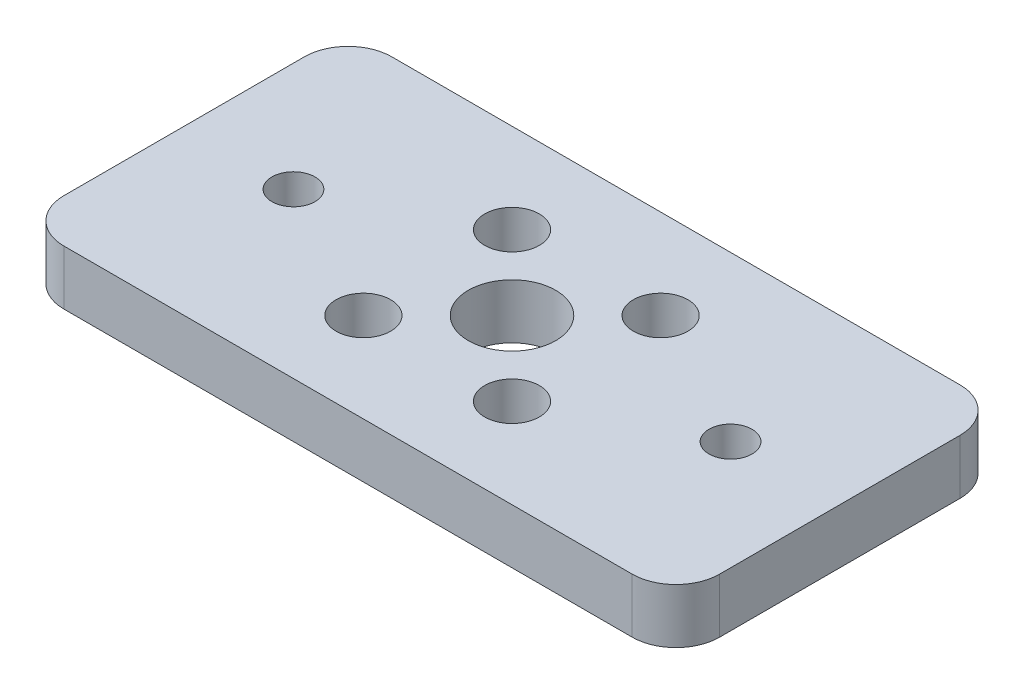
from build123d import *

# Parameters (mm, degrees)
SKETCH1_W             = 38.1
SKETCH1_H             = 19.05
SKETCH1_R             = 2.54
BOSS_EXTRUDE1_DEPTH   = 3.175
SKETCH2_R             = 1.5875
CUT_EXTRUDE1_DEPTH    = 4.175
F_2_5MM_DOWEL_HOLE1_D = 2.5
FILLET1_R             = 2.54


with BuildPart() as part:
    # Sketch1 → Boss-Extrude1 (new body)
    with BuildSketch(Plane(origin=(0, 0, 0), x_dir=(1, 0, 0), z_dir=(0, 1, 0))):
        Rectangle(SKETCH1_W, SKETCH1_H)
        Circle(SKETCH1_R, mode=Mode.SUBTRACT)
    extrude(amount=BOSS_EXTRUDE1_DEPTH)

    # Sketch2 → Cut-Extrude1 (cut, through all)
    with BuildSketch(Plane(origin=(0, 3.175, 0), x_dir=(1, 0, 0), z_dir=(0, 1, 0))):
        with Locations((-4.318, 4.318)):
            Circle(SKETCH2_R)
        with Locations((4.318, 4.318)):
            Circle(SKETCH2_R)
        with Locations((-4.318, -4.318)):
            Circle(SKETCH2_R)
        with Locations((4.318, -4.318)):
            Circle(SKETCH2_R)
    extrude(amount=-CUT_EXTRUDE1_DEPTH, mode=Mode.SUBTRACT)

    # Ø2.5mm Dowel Hole1 (through all)
    with Locations(Plane(origin=(0, 3.175, 0), x_dir=(1, 0, 0), z_dir=(0, 1, 0))):
        with Locations((12.7, 0), (-12.7, 0)):
            Hole(F_2_5MM_DOWEL_HOLE1_D / 2)

    # Fillet1
    fillet1_edges = [part.edges().sort_by_distance(p)[0] for p in [
        (19.05, 1.5875, 9.525),
        (-19.05, 1.5875, 9.525),
        (-19.05, 1.5875, -9.525),
        (19.05, 1.5875, -9.525),
    ]]
    fillet(fillet1_edges, radius=FILLET1_R)


solid = part.part
